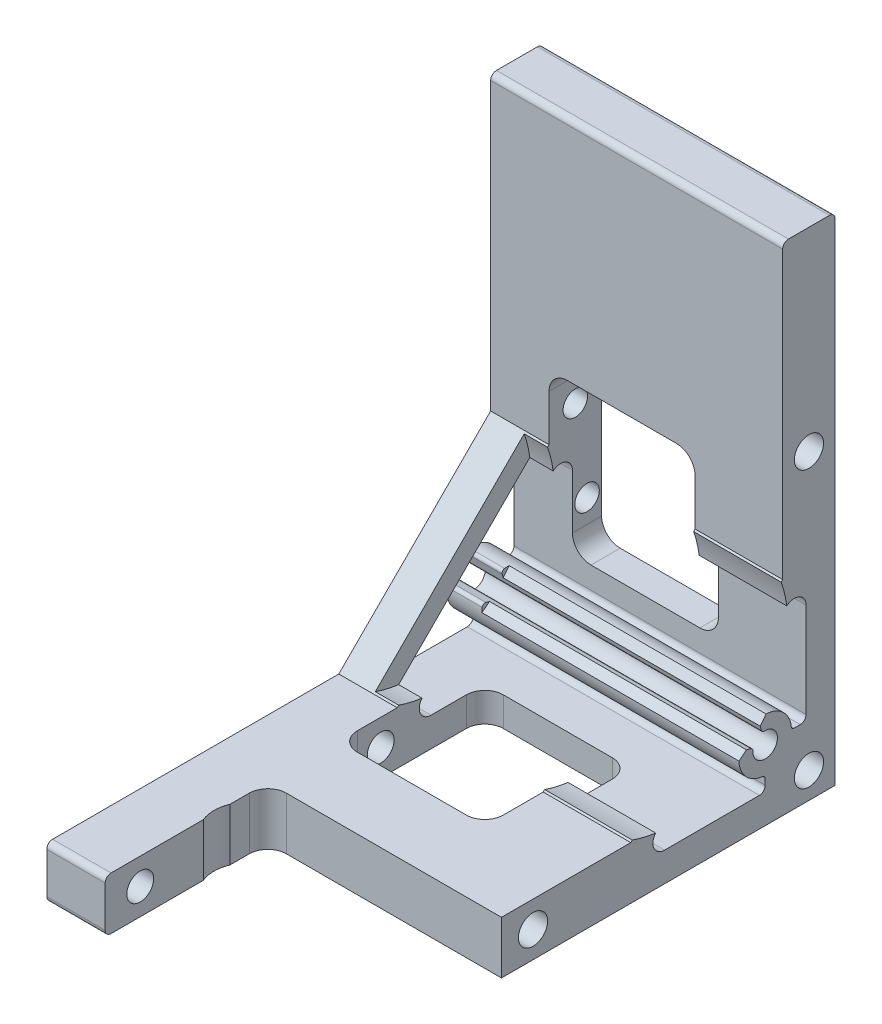
from build123d import *

# Parameters (mm, degrees)
STRUCTURAL_MEMBER1_DEPTH = 50
SKETCH16_R               = 2.5
CUT_EXTRUDE2_DEPTH       = 20
CUT_EXTRUDE7_REACH       = 116.8
CUT_EXTRUDE8_REACH       = 116.708
SKETCH23_R               = 2.1
CUT_EXTRUDE9_REACH       = 116.8
CUT_EXTRUDE10_REACH      = 112.716
SKETCH25_R               = 2.3
SKETCH26_R               = 6
CUT_EXTRUDE11_DEPTH      = 115.799827021


with BuildPart() as part:
    # Sketch14 → Structural Member1 (new body)
    with BuildSketch(Plane.YZ.offset(-25)):
        with BuildLine():
            Line((-11.999992417, -11.999998055), (72.000007583, -11.999998055))
            ThreePointArc((72.000007583, -11.999998055), (72.707114364, -11.707104836), (73.000007583, -10.999998055))
            Line((73.000007583, -10.999998055), (73.000007583, -3.999995305))
            ThreePointArc((73.000007583, -3.999995305), (72.707113392, -3.292890301), (72.000007583, -2.999998055))
            Line((72.000007583, -2.999998055), (23.000007583, -2.999998055))
            Line((23.000007583, -2.999998055), (-2.999992417, 23.000001945))
            Line((-2.999992417, 23.000001945), (-2.999992417, 72.000001945))
            ThreePointArc((-2.999992417, 72.000001945), (-3.292885636, 72.707108727), (-3.999992417, 73.000001945))
            Line((-3.999992417, 73.000001945), (-10.999992417, 73.000001945))
            ThreePointArc((-10.999992417, 73.000001945), (-11.707099198, 72.707108727), (-11.999992417, 72.000001945))
            Line((-11.999992417, 72.000001945), (-11.999992417, -11.999998055))
        make_face()
        with BuildLine():
            Line((0.999999969, -6.999999689), (17.221834624, -6.999999689))
            ThreePointArc((17.221834624, -6.999999689), (19.069593689, -5.765366553), (18.636048187, -3.585786126))
            Line((18.636048187, -3.585786126), (-3.585808896, 18.636070956))
            ThreePointArc((-3.585808896, 18.636070956), (-5.765389323, 19.069616459), (-7.000022459, 17.221857394))
            Line((-7.000022459, 17.221857394), (-7.000022459, 1.000002257))
            ThreePointArc((-7.000022459, 1.000002257), (-6.707129334, 0.29289557), (-6.000022726, 2.257e-06))
            Line((-6.000022726, 2.257e-06), (-4.974936959, 2.257e-06))
            ThreePointArc((-4.974936959, 2.257e-06), (-4.639527617, 0.129191559), (-4.477443471, 0.449999963))
            ThreePointArc((-4.477443471, 0.449999963), (-2.784112909, 3.535352218), (0.612237786, 4.458157119))
            ThreePointArc((0.612237786, 4.458157119), (0.960727975, 4.239434815), (1.027186757, 3.833395301))
            Line((1.027186757, 3.833395301), (0.660400741, 2.464528966))
            ThreePointArc((0.660400741, 2.464528966), (0.468097556, 2.187100615), (0.143315125, 2.095104001))
            ThreePointArc((0.143315125, 2.095104001), (-1.484932492, -1.484915989), (2.095105594, 0.14329184))
            ThreePointArc((2.095105594, 0.14329184), (2.18710419, 0.46807097), (2.464530895, 0.6603719))
            Line((2.464530895, 0.6603719), (3.83339913, 1.027158555))
            ThreePointArc((3.83339913, 1.027158555), (4.2394351, 0.960702167), (4.458159824, 0.612218085))
            ThreePointArc((4.458159824, 0.612218085), (3.535346067, -2.784120721), (0.449999963, -4.477443471))
            ThreePointArc((0.449999963, -4.477443471), (0.129190042, -4.639526994), (-3.1e-08, -4.974937189))
            Line((-3.1e-08, -4.974937189), (-3.1e-08, -5.999999623))
            ThreePointArc((-3.1e-08, -5.999999623), (0.292893164, -6.707106447), (0.999999969, -6.999999689))
        make_face(mode=Mode.SUBTRACT)
    extrude(amount=STRUCTURAL_MEMBER1_DEPTH)

    # Sketch16 → Cut-Extrude2 (cut)
    with BuildSketch(Plane(origin=(25, 0, 0), x_dir=(0, 0, -1), z_dir=(1, 0, 0))):
        with Locations((7.499998055, -7.499992417)):
            Circle(SKETCH16_R)
        with Locations((-39.744001945, -7.499992417)):
            Circle(SKETCH16_R)
        with Locations((7.499998055, 39.744007583)):
            Circle(SKETCH16_R)
    extrude(amount=-CUT_EXTRUDE2_DEPTH, mode=Mode.SUBTRACT)

    # Sketch18 → Cut-Revolve1 (revolve, cut)
    with BuildSketch(Plane(origin=(0, 2.977207172, 29.266802357), x_dir=(-1, 0, 0), z_dir=(0, 0.7071067811865477, 0.7071067811865475))):
        Polygon((-25, -38.589555017), (19, -38.589555017), (19, -21.764555017), (25, -21.764555017), (25, -18.589555017), (-25, -18.589555017), align=None)
    revolve(axis=Axis((25, 16.122007583, 16.122001945), (1, 0, 0)), mode=Mode.SUBTRACT)

    # Sketch22 → Cut-Extrude7 (cut, up to next)
    with BuildSketch(Plane(origin=(0, 0, -11.999998055), x_dir=(-1, 0, 0), z_dir=(0, 0, -1)), mode=Mode.PRIVATE) as cut_extrude7_sk1:
        with BuildLine():
            Line((11.825, 4.747007583), (-6.825, 4.747007583))
            ThreePointArc((-6.825, 4.747007583), (-9.07006403, 5.676943553), (-10, 7.922007583))
            Line((-10, 7.922007583), (-10, 30.922007583))
            ThreePointArc((-10, 30.922007583), (-9.07006403, 33.167071613), (-6.825, 34.097007583))
            Line((-6.825, 34.097007583), (11.825, 34.097007583))
            ThreePointArc((11.825, 34.097007583), (14.07006403, 33.167071613), (15, 30.922007583))
            Line((15, 30.922007583), (15, 7.922007583))
            ThreePointArc((15, 7.922007583), (14.07006403, 5.676943553), (11.825, 4.747007583))
        make_face()
    cut_extrude7_tool1 = extrude(cut_extrude7_sk1.sketch, amount=-CUT_EXTRUDE7_REACH, mode=Mode.PRIVATE) & part.part
    add(cut_extrude7_tool1.solids().sort_by_distance((-2.5, 19.422008, -11.999998))[0], mode=Mode.SUBTRACT)

    # Sketch23 → Cut-Extrude8 (cut, up to next)
    with BuildSketch(Plane.ZY.offset(25), mode=Mode.PRIVATE) as cut_extrude8_sk1:
        with Locations((-9.499998872, 11.922007583)):
            Circle(SKETCH23_R)
    cut_extrude8_tool1 = extrude(cut_extrude8_sk1.sketch, amount=-CUT_EXTRUDE8_REACH, mode=Mode.PRIVATE) & part.part
    # Sketch23 → Cut-Extrude8 (cut, up to next)
    with BuildSketch(Plane.ZY.offset(25), mode=Mode.PRIVATE) as cut_extrude8_sk2:
        with Locations((-7.499998055, 26.922007583)):
            Circle(SKETCH23_R)
    cut_extrude8_tool2 = extrude(cut_extrude8_sk2.sketch, amount=-CUT_EXTRUDE8_REACH, mode=Mode.PRIVATE) & part.part
    add(cut_extrude8_tool1.solids().sort_by_distance((-25, 11.922008, -9.499999))[0], mode=Mode.SUBTRACT)
    add(cut_extrude8_tool2.solids().sort_by_distance((-25, 26.922008, -7.499998))[0], mode=Mode.SUBTRACT)

    # Sketch24 → Cut-Extrude9 (cut, up to next)
    with BuildSketch(Plane.XZ.offset(11.999992417), mode=Mode.PRIVATE) as cut_extrude9_sk1:
        with BuildLine():
            Line((6.825, 8.000001945), (-11.825, 8.000001945))
            ThreePointArc((-11.825, 8.000001945), (-14.07006403, 8.929937915), (-15, 11.175001945))
            Line((-15, 11.175001945), (-15, 29.825001945))
            ThreePointArc((-15, 29.825001945), (-14.07006403, 32.070065976), (-11.825, 33.000001945))
            Line((-11.825, 33.000001945), (6.825, 33.000001945))
            ThreePointArc((6.825, 33.000001945), (9.07006403, 32.070065976), (10, 29.825001945))
            Line((10, 29.825001945), (10, 11.175001945))
            ThreePointArc((10, 11.175001945), (9.07006403, 8.929937915), (6.825, 8.000001945))
        make_face()
    cut_extrude9_tool1 = extrude(cut_extrude9_sk1.sketch, amount=-CUT_EXTRUDE9_REACH, mode=Mode.PRIVATE) & part.part
    # Sketch24 → Cut-Extrude9 (cut, up to next)
    with BuildSketch(Plane.XZ.offset(11.999992417), mode=Mode.PRIVATE) as cut_extrude9_sk2:
        with BuildLine():
            Line((25, 73.000001945), (-15, 73.000001945))
            Line((-15, 73.000001945), (-15, 48.325001945))
            ThreePointArc((-15, 48.325001945), (-14.07006403, 46.079937915), (-11.825, 45.150001945))
            Line((-11.825, 45.150001945), (25, 45.150001945))
            Line((25, 45.150001945), (25, 73.000001945))
        make_face()
    cut_extrude9_tool2 = extrude(cut_extrude9_sk2.sketch, amount=-CUT_EXTRUDE9_REACH, mode=Mode.PRIVATE) & part.part
    add(cut_extrude9_tool1.solids().sort_by_distance((-2.5, -11.999992, 20.500002))[0], mode=Mode.SUBTRACT)
    add(cut_extrude9_tool2.solids().sort_by_distance((5.037534, -11.999992, 59.100716))[0], mode=Mode.SUBTRACT)

    # Sketch25 → Cut-Extrude10 (cut, up to next)
    with BuildSketch(Plane(origin=(-15, 0, 0), x_dir=(0, 0, -1), z_dir=(1, 0, 0)), mode=Mode.PRIVATE) as cut_extrude10_sk1:
        with Locations((-67.000001945, -7.499992417)):
            Circle(SKETCH25_R)
    cut_extrude10_tool1 = extrude(cut_extrude10_sk1.sketch, amount=-CUT_EXTRUDE10_REACH, mode=Mode.PRIVATE) & part.part
    # Sketch25 → Cut-Extrude10 (cut, up to next)
    with BuildSketch(Plane(origin=(-15, 0, 0), x_dir=(0, 0, -1), z_dir=(1, 0, 0)), mode=Mode.PRIVATE) as cut_extrude10_sk2:
        with Locations((-25.825001945, -7.499992417)):
            Circle(SKETCH25_R)
    cut_extrude10_tool2 = extrude(cut_extrude10_sk2.sketch, amount=-CUT_EXTRUDE10_REACH, mode=Mode.PRIVATE) & part.part
    add(cut_extrude10_tool1.solids().sort_by_distance((-15, -7.499992, 67.000002))[0], mode=Mode.SUBTRACT)
    add(cut_extrude10_tool2.solids().sort_by_distance((-15, -7.499992, 25.825002))[0], mode=Mode.SUBTRACT)

    # Sketch26 → Cut-Extrude11 (cut, through all)
    with BuildSketch(Plane.XZ.offset(11.999992417)):
        with Locations((-9.455, 53.912001945)):
            Circle(SKETCH26_R)
    extrude(amount=-CUT_EXTRUDE11_DEPTH, mode=Mode.SUBTRACT)


solid = part.part
